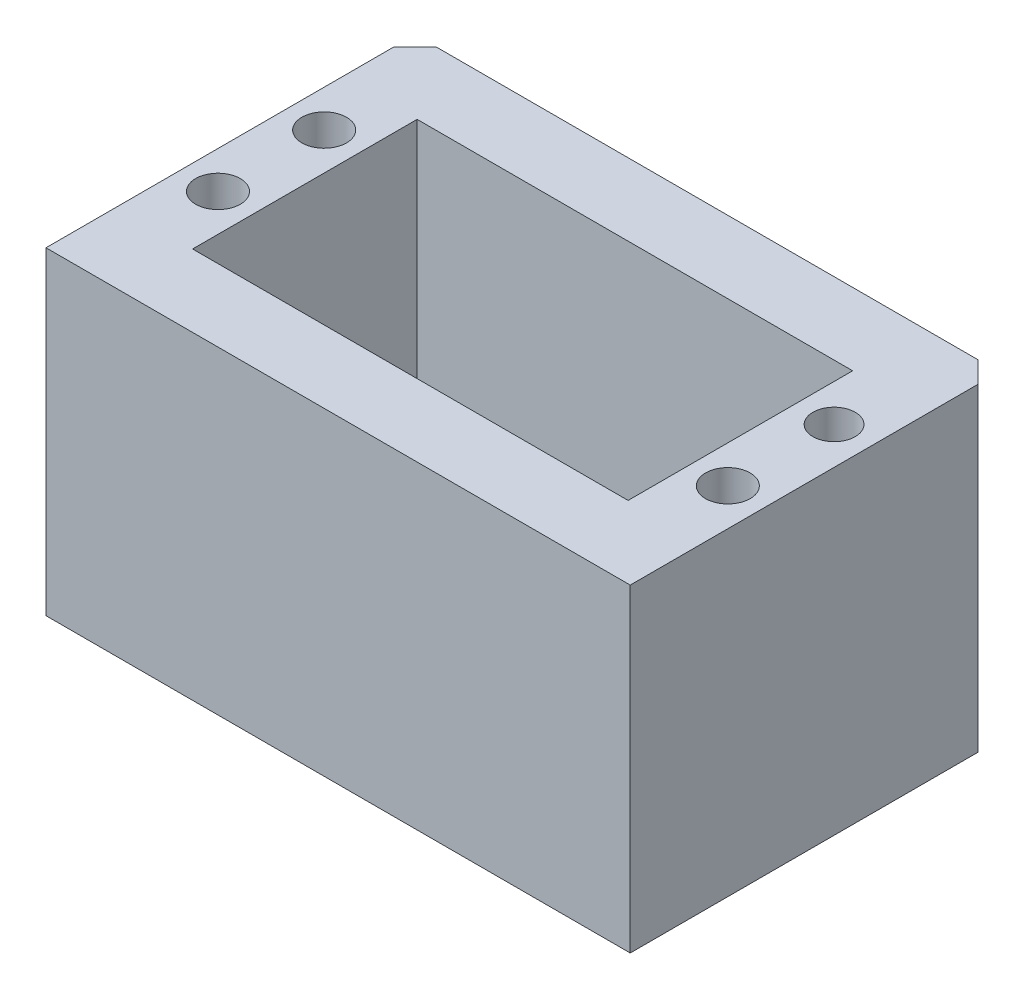
from build123d import *

# Parameters (mm, degrees)
SKETCH1_W           = 55
SKETCH1_H           = 34.740153272
BOSS_EXTRUDE1_DEPTH = 30
SKETCH3_W           = 41
SKETCH3_H           = 21.140153272
CUT_EXTRUDE1_DEPTH  = 28.87
SKETCH5_W           = 7
SKETCH5_H           = 4.2
CUT_EXTRUDE2_DEPTH  = 10
SKETCH6_R           = 2.1
SKETCH6_R_2         = 1.99312569
CUT_EXTRUDE3_DEPTH  = 7
SKETCH7_R           = 4
BOSS_EXTRUDE2_DEPTH = 12
CHAMFER1_SIZE       = 2


with BuildPart() as part:
    # Sketch1 → Boss-Extrude1 (new body)
    with BuildSketch(Plane(origin=(0, 0, 0), x_dir=(1, 0, 0), z_dir=(0, 1, 0))):
        with Locations((27.5, 17.370076636)):
            Rectangle(SKETCH1_W, SKETCH1_H)
    extrude(amount=BOSS_EXTRUDE1_DEPTH)

    # Sketch3 → Cut-Extrude1 (cut)
    with BuildSketch(Plane(origin=(0, 30, 0), x_dir=(1, 0, 0), z_dir=(0, 1, 0))):
        with Locations((27.5, 17.370076636)):
            Rectangle(SKETCH3_W, SKETCH3_H)
    extrude(amount=-CUT_EXTRUDE1_DEPTH, mode=Mode.SUBTRACT)

    # Sketch5 → Cut-Extrude2 (cut)
    with BuildSketch(Plane.ZY):
        with Locations((-17.690153272, 6.5)):
            Rectangle(SKETCH5_W, SKETCH5_H)
    extrude(amount=-CUT_EXTRUDE2_DEPTH, mode=Mode.SUBTRACT)

    # Sketch6 → Cut-Extrude3 (cut)
    with BuildSketch(Plane(origin=(0, 30, 0), x_dir=(1, 0, 0), z_dir=(0, 1, 0))):
        with Locations((3.5, 22.690153272)):
            Circle(SKETCH6_R)
        with Locations((3.5, 12.690153272)):
            Circle(SKETCH6_R)
        with Locations((51.5, 12.690153272)):
            Circle(SKETCH6_R)
        with Locations((51.5, 22.690153272)):
            Circle(SKETCH6_R_2)
    extrude(amount=-CUT_EXTRUDE3_DEPTH, mode=Mode.SUBTRACT)

    # Sketch7 → Boss-Extrude2 (add)
    with BuildSketch(Plane.XZ):
        with Locations((17.25, -17.690153272)):
            Circle(SKETCH7_R)
    extrude(amount=BOSS_EXTRUDE2_DEPTH)

    # Chamfer1
    chamfer1_edges = [part.edges().sort_by_distance(p)[0] for p in [
        (0, 15, -34.740153272),
        (55, 15, -34.740153272),
    ]]
    chamfer(chamfer1_edges, length=CHAMFER1_SIZE)


solid = part.part
